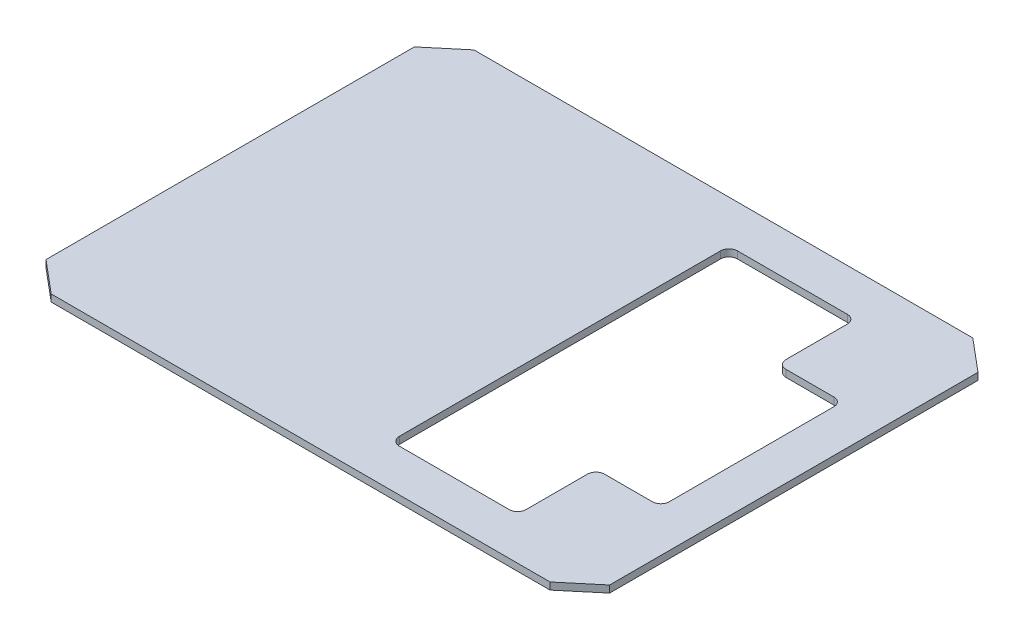
from build123d import *

# Parameters (mm, degrees)
BOSS_EXTRUDE1_DEPTH = 3.175
CUT_EXTRUDE1_DEPTH  = 4.175


with BuildPart() as part:
    # Sketch1 → Boss-Extrude1 (new body)
    with BuildSketch(Plane(origin=(0, 0, 0), x_dir=(1, 0, 0), z_dir=(0, 1, 0))):
        Polygon((127, -83.004896035), (112.406853359, -95.25), (-112.406853359, -95.25), (-127, -83.004896035), (-127, 83.004896035), (-112.406853359, 95.25), (112.406853359, 95.25), (127, 83.004896035), align=None)
    extrude(amount=BOSS_EXTRUDE1_DEPTH)

    # Sketch2 → Cut-Extrude1 (cut, through all)
    with BuildSketch(Plane(origin=(0, 3.175, 0), x_dir=(1, 0, 0), z_dir=(0, 1, 0))):
        with BuildLine():
            Line((82.55, 40.894), (104.14, 40.894))
            ThreePointArc((104.14, 40.894), (106.834076836, 39.778076836), (107.95, 37.084))
            Line((107.95, 37.084), (107.95, -37.084))
            ThreePointArc((107.95, -37.084), (106.834076836, -39.778076836), (104.14, -40.894))
            Line((104.14, -40.894), (82.55, -40.894))
            ThreePointArc((82.55, -40.894), (79.855923164, -42.009923164), (78.74, -44.704))
            Line((78.74, -44.704), (78.74, -72.39))
            ThreePointArc((78.74, -72.39), (77.624076836, -75.084076836), (74.93, -76.2))
            Line((74.93, -76.2), (25.4, -76.2))
            ThreePointArc((25.4, -76.2), (22.705923164, -75.084076836), (21.59, -72.39))
            Line((21.59, -72.39), (21.59, 72.39))
            ThreePointArc((21.59, 72.39), (22.705923164, 75.084076836), (25.4, 76.2))
            Line((25.4, 76.2), (74.93, 76.2))
            ThreePointArc((74.93, 76.2), (77.624076836, 75.084076836), (78.74, 72.39))
            Line((78.74, 72.39), (78.74, 44.704))
            ThreePointArc((78.74, 44.704), (79.855923164, 42.009923164), (82.55, 40.894))
        make_face()
    extrude(amount=-CUT_EXTRUDE1_DEPTH, mode=Mode.SUBTRACT)


solid = part.part
